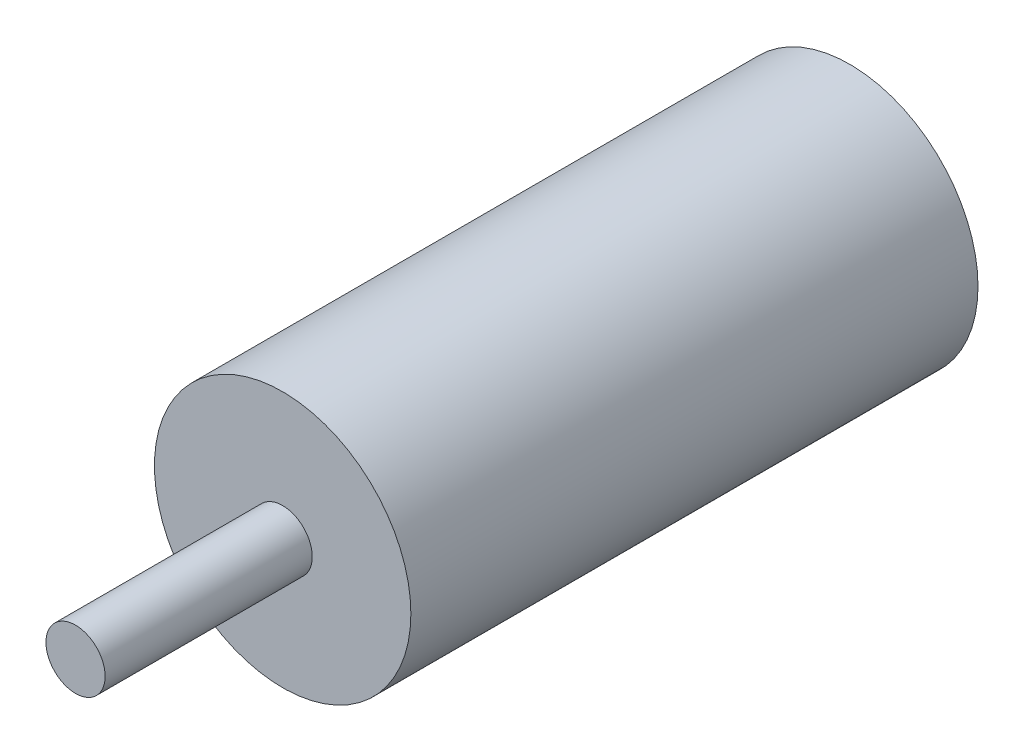
from build123d import *

# Parameters (mm, degrees)
SKETCH1_R           = 26
BOSS_EXTRUDE1_DEPTH = 115
SKETCH2_R           = 6
BOSS_EXTRUDE2_DEPTH = 42


with BuildPart() as part:
    # Sketch1 → Boss-Extrude1 (new body)
    with BuildSketch(Plane.XY):
        Circle(SKETCH1_R)
    extrude(amount=BOSS_EXTRUDE1_DEPTH)

    # Sketch2 → Boss-Extrude2 (add)
    with BuildSketch(Plane.XY.offset(115)):
        Circle(SKETCH2_R)
    extrude(amount=BOSS_EXTRUDE2_DEPTH)


solid = part.part
